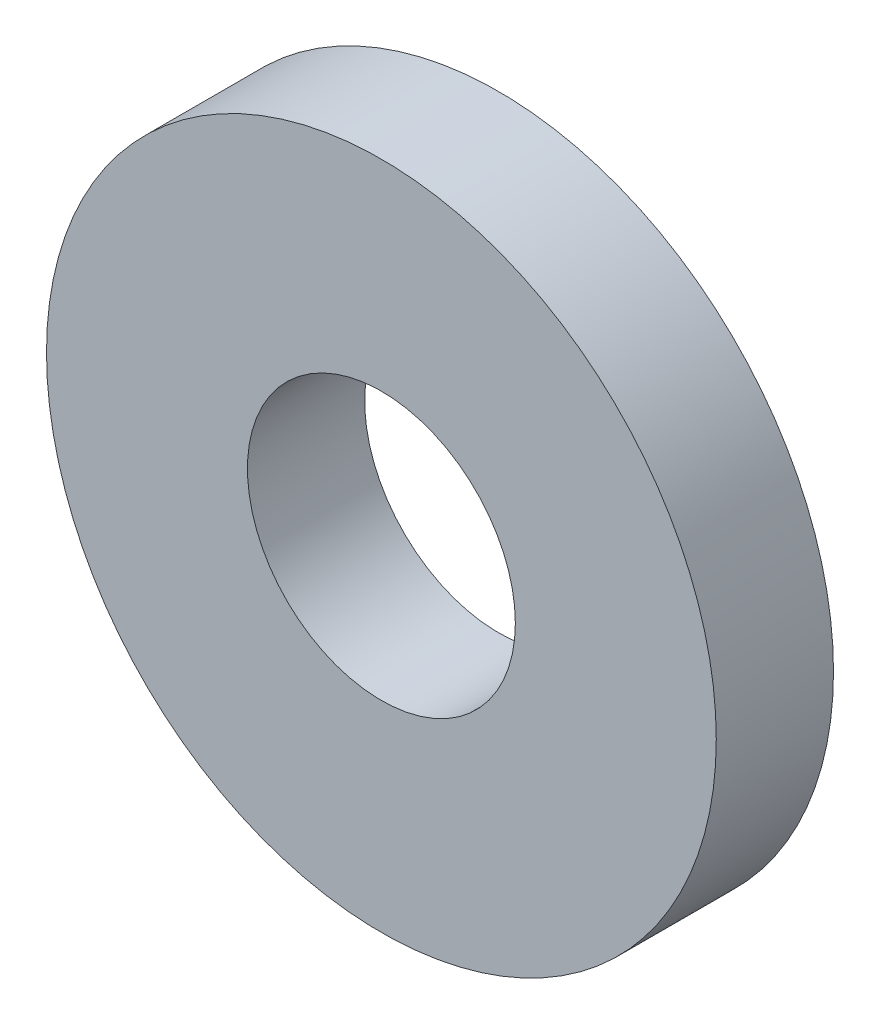
from build123d import *

# Parameters (mm, degrees)
SKETCH_1_R      = 4
SKETCH_1_R_2    = 1.6
EXTRUDE_1_DEPTH = 1.4


with BuildPart() as part:
    # Эскиз1 → Бобышка-Вытянуть1 (new body)
    with BuildSketch(Plane.XY):
        Circle(SKETCH_1_R)
        Circle(SKETCH_1_R_2, mode=Mode.SUBTRACT)
    extrude(amount=EXTRUDE_1_DEPTH)


solid = part.part
